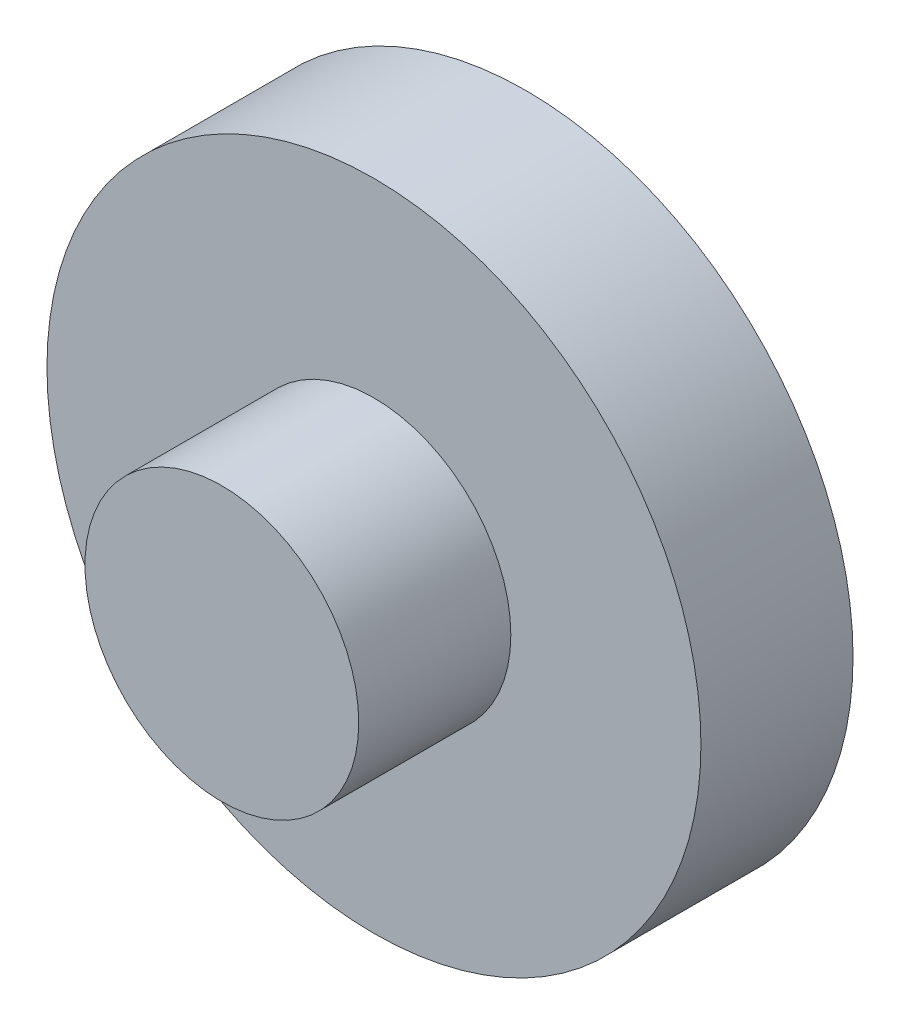
from build123d import *

# Parameters (mm, degrees)
SKETCH1_R           = 5.461
BOSS_EXTRUDE1_DEPTH = 2.54
SKETCH2_R           = 2.286
BOSS_EXTRUDE2_DEPTH = 2.54


with BuildPart() as part:
    # Sketch1 → Boss-Extrude1 (new body)
    with BuildSketch(Plane.XY):
        Circle(SKETCH1_R)
    extrude(amount=BOSS_EXTRUDE1_DEPTH)

    # Sketch2 → Boss-Extrude2 (add)
    with BuildSketch(Plane.XY.offset(2.54)):
        Circle(SKETCH2_R)
    extrude(amount=BOSS_EXTRUDE2_DEPTH)


solid = part.part
